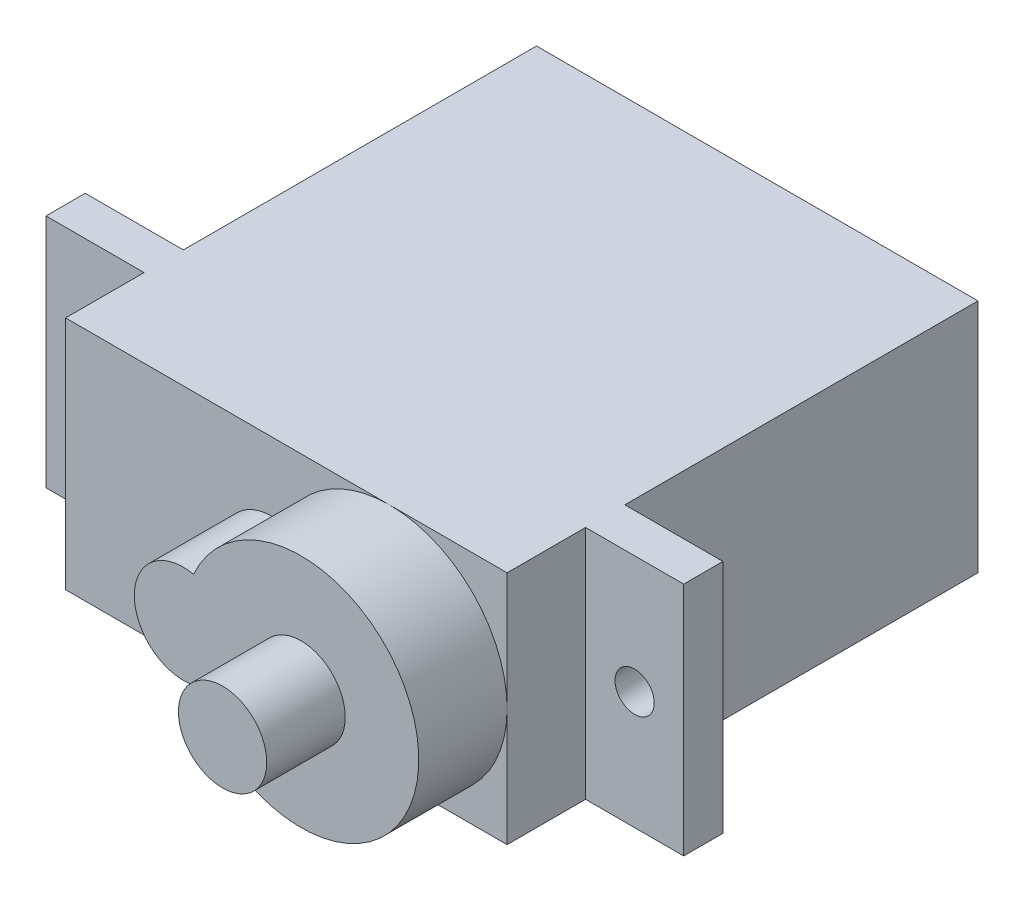
from build123d import *

# Parameters (mm, degrees)
SKETCH1_W      = 22.5
SKETCH1_H      = 12
EXTRUDE1_DEPTH = 18
SKETCH2_W      = 32.5
SKETCH2_H      = 12
EXTRUDE2_DEPTH = 2
SKETCH3_W      = 22.5
SKETCH3_H      = 12
EXTRUDE3_DEPTH = 4
SKETCH4_R      = 1
EXTRUDE4_DEPTH = 21
EXTRUDE5_DEPTH = 4.5
SKETCH6_R      = 2.25
EXTRUDE6_DEPTH = 4


with BuildPart() as part:
    # Sketch1 → Extrude1 (new body)
    with BuildSketch(Plane.XY):
        Rectangle(SKETCH1_W, SKETCH1_H)
    extrude(amount=EXTRUDE1_DEPTH)

    # Sketch2 → Extrude2 (add)
    with BuildSketch(Plane.XY.offset(18)):
        Rectangle(SKETCH2_W, SKETCH2_H)
    extrude(amount=EXTRUDE2_DEPTH)

    # Sketch3 → Extrude3 (add)
    with BuildSketch(Plane.XY.offset(20)):
        Rectangle(SKETCH3_W, SKETCH3_H)
    extrude(amount=EXTRUDE3_DEPTH)

    # Sketch4 → Extrude4 (cut, through all)
    with BuildSketch(Plane.XY.offset(20)):
        with Locations((-13.75, 0)):
            Circle(SKETCH4_R)
        with Locations((13.75, 0)):
            Circle(SKETCH4_R)
    extrude(amount=-EXTRUDE4_DEPTH, mode=Mode.SUBTRACT)

    # Sketch5 → Extrude5 (add)
    with BuildSketch(Plane.XY.offset(24)):
        with BuildLine():
            ThreePointArc((-0.229166667, -2.445144707), (11.25, 0), (-0.229166667, 2.445144707))
            ThreePointArc((-0.229166667, 2.445144707), (-3.25, 0), (-0.229166667, -2.445144707))
        make_face()
    extrude(amount=EXTRUDE5_DEPTH)

    # Sketch6 → Extrude6 (add)
    with BuildSketch(Plane.XY.offset(28.5)):
        with Locations((5.25, 0)):
            Circle(SKETCH6_R)
    extrude(amount=EXTRUDE6_DEPTH)


solid = part.part
